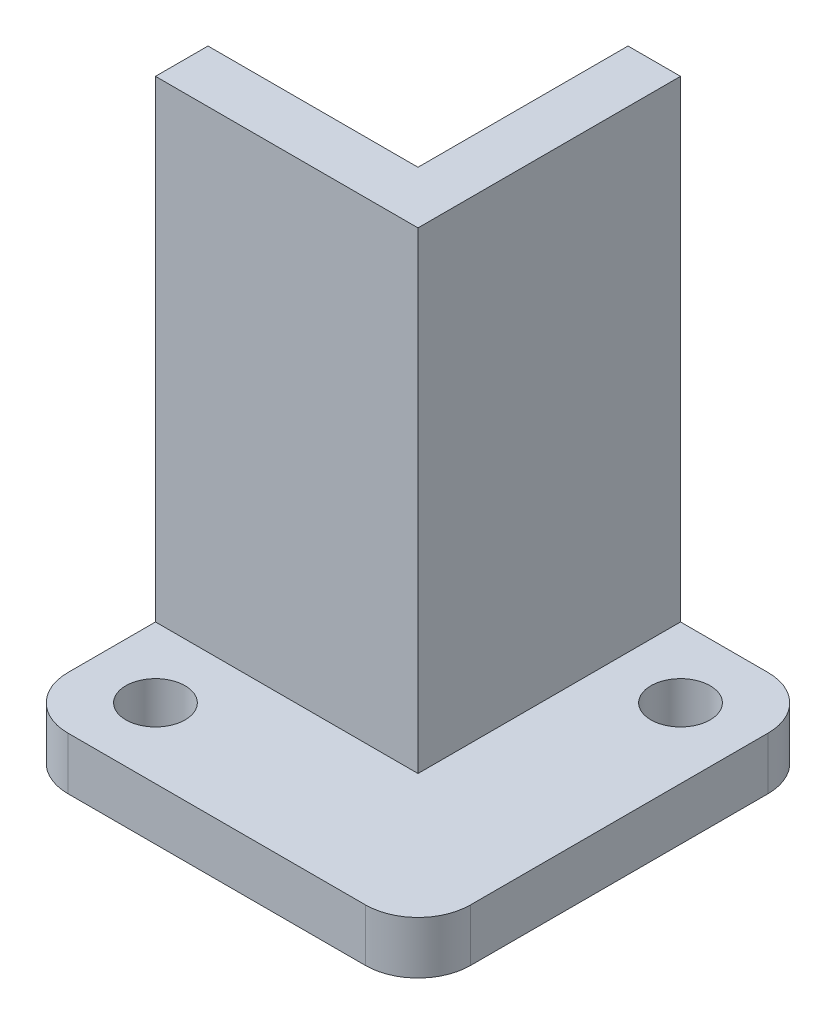
from build123d import *

# Parameters (mm, degrees)
BOSS_EXTRUDE1_DEPTH = 3.81
BOSS_EXTRUDE2_DEPTH = 34.29
SKETCH3_R           = 2.15
CUT_EXTRUDE1_DEPTH  = 4.81
FILLET1_R           = 3.81


with BuildPart() as part:
    # Sketch1 → Boss-Extrude1 (new body)
    with BuildSketch(Plane(origin=(0, 0, 0), x_dir=(1, 0, 0), z_dir=(0, 1, 0))):
        Polygon((29.21, 0), (29.21, 29.21), (15.24, 29.21), (15.24, 13.97), (0, 13.97), (0, 0), align=None)
    extrude(amount=BOSS_EXTRUDE1_DEPTH)

    # Sketch2 → Boss-Extrude2 (add)
    with BuildSketch(Plane(origin=(0, 3.81, 0), x_dir=(1, 0, 0), z_dir=(0, 1, 0))):
        Polygon((0, 13.97), (15.24, 13.97), (15.24, 29.21), (19.05, 29.21), (19.05, 10.16), (0, 10.16), align=None)
    extrude(amount=BOSS_EXTRUDE2_DEPTH)

    # Sketch3 → Cut-Extrude1 (cut, through all)
    with BuildSketch(Plane(origin=(0, 3.81, 0), x_dir=(1, 0, 0), z_dir=(0, 1, 0))):
        with Locations((5.08, 5.08)):
            Circle(SKETCH3_R)
        with Locations((24.13, 24.13)):
            Circle(SKETCH3_R)
    extrude(amount=-CUT_EXTRUDE1_DEPTH, mode=Mode.SUBTRACT)

    # Fillet1
    fillet1_edges = [part.edges().sort_by_distance(p)[0] for p in [
        (29.21, 1.905, -29.21),
        (29.21, 1.905, 0),
        (0, 1.905, 0),
    ]]
    fillet(fillet1_edges, radius=FILLET1_R)


solid = part.part
